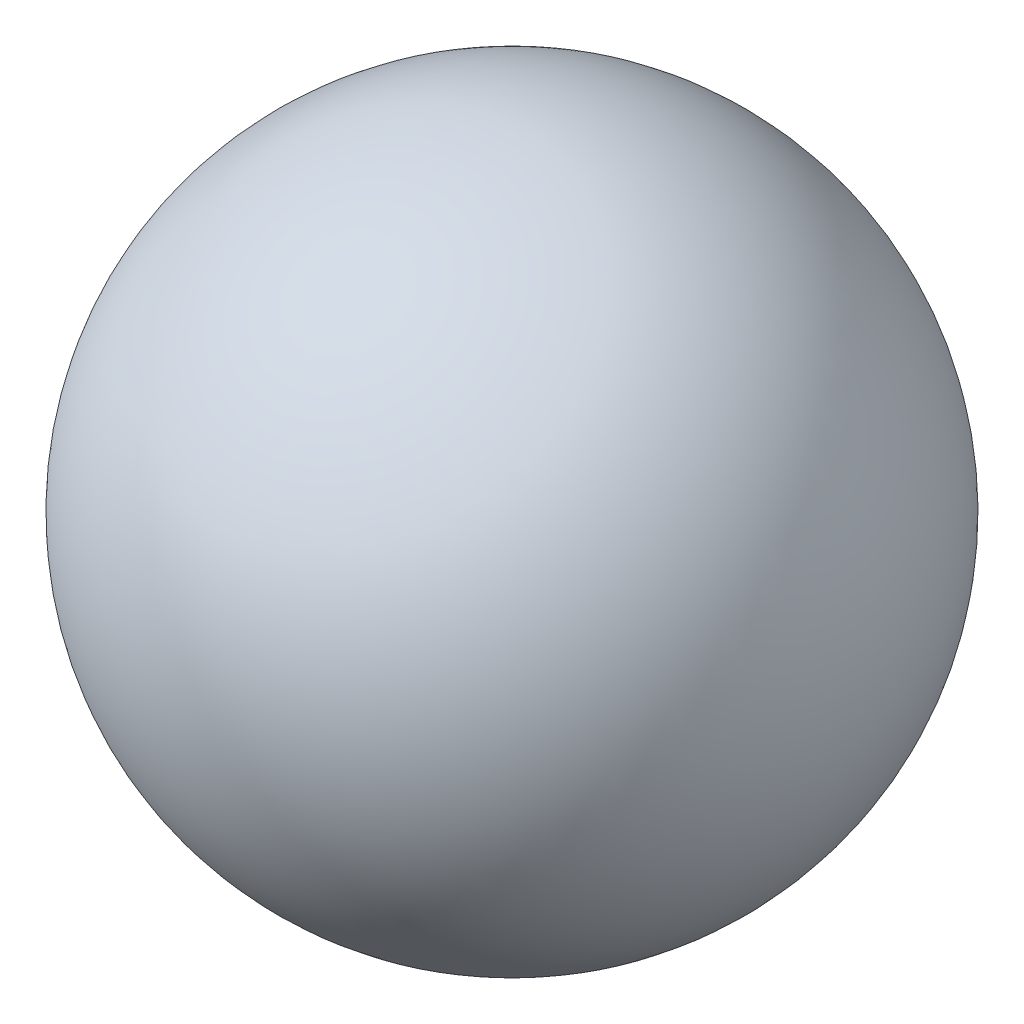
from build123d import *


with BuildPart() as part:
    # Skizze1 → Rotation1 (revolve)
    with BuildSketch(Plane.XY):
        with BuildLine():
            Line((11, -16.703293088), (3.3235, -16.703293088))
            Line((3.3235, -16.703293088), (3.3235, -0.703293088))
            Line((3.3235, -0.703293088), (0, 1.293667179))
            Line((0, 1.293667179), (0, 20))
            ThreePointArc((0, 20), (19.15810353, 5.741695665), (11, -16.703293088))
        make_face()
    revolve(axis=Axis((0, 35.693338508, 0), (0, -1, 0)))


solid = part.part
